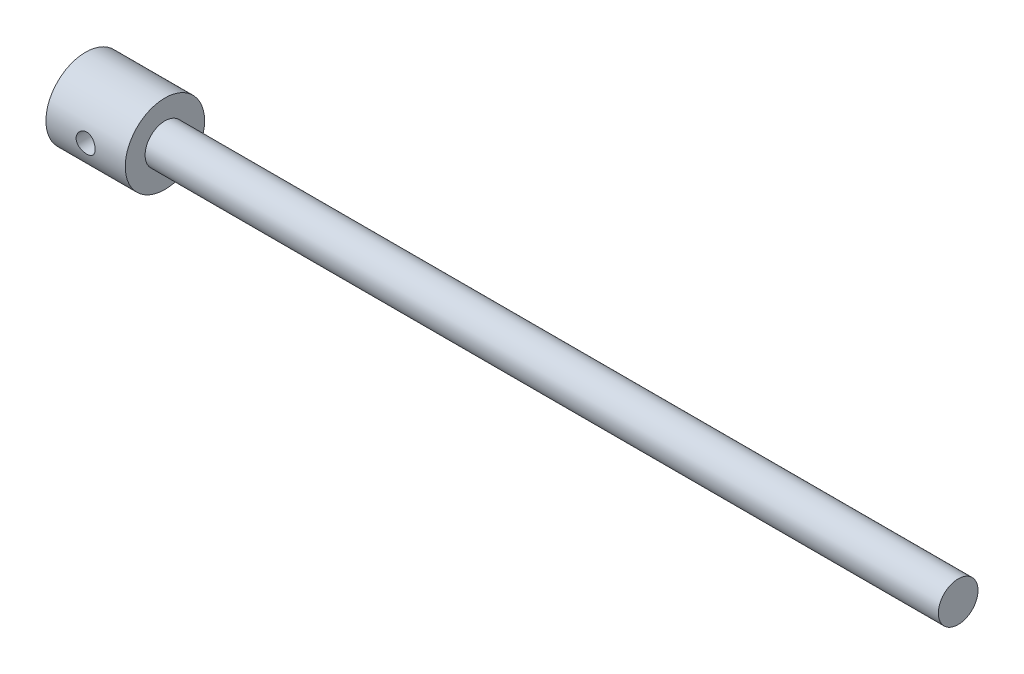
from build123d import *

# Parameters (mm, degrees)
SKETCH1_R               = 25
BOSS_EXTRUDE1_DEPTH     = 50
SKETCH2_R               = 6
CUT_EXTRUDE1_DEPTH      = 26
CUT_EXTRUDE1_DEPTH_BACK = 60
SKETCH3_R               = 12.5
BOSS_EXTRUDE2_DEPTH     = 500


with BuildPart() as part:
    # Sketch1 → Boss-Extrude1 (new body)
    with BuildSketch(Plane(origin=(0, 0, 0), x_dir=(0, 0, -1), z_dir=(1, 0, 0))):
        Circle(SKETCH1_R)
    extrude(amount=BOSS_EXTRUDE1_DEPTH)

    # Sketch2 → Cut-Extrude1 (cut, two sides)
    with BuildSketch(Plane.XY) as cut_extrude1_sk:
        with Locations((25, 0)):
            Circle(SKETCH2_R)
    extrude(amount=CUT_EXTRUDE1_DEPTH, mode=Mode.SUBTRACT)
    extrude(cut_extrude1_sk.sketch, amount=-CUT_EXTRUDE1_DEPTH_BACK, mode=Mode.SUBTRACT)

    # Sketch3 → Boss-Extrude2 (add)
    with BuildSketch(Plane(origin=(50, 0, 0), x_dir=(0, 0, -1), z_dir=(1, 0, 0))):
        Circle(SKETCH3_R)
    extrude(amount=BOSS_EXTRUDE2_DEPTH)


solid = part.part
